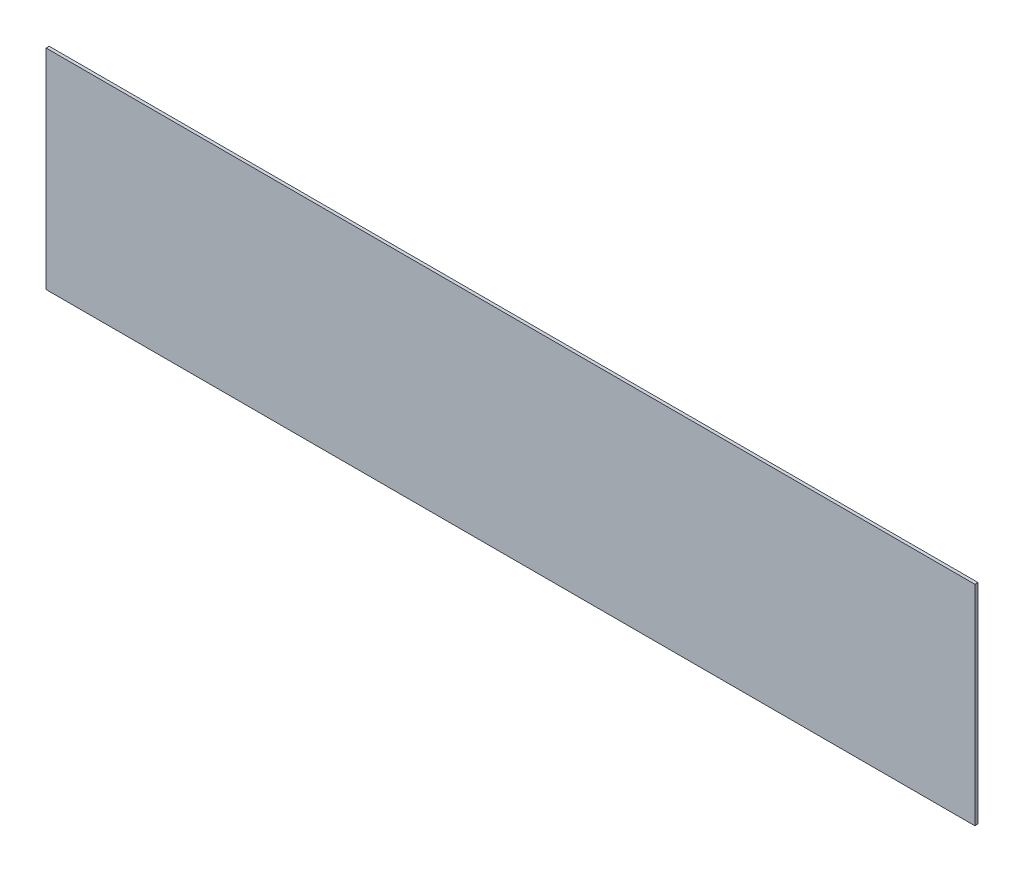
from build123d import *

# Parameters (mm, degrees)
ESBO_O1_W                = 1199
ESBO_O1_H                = 270
RESSALTO_EXTRUS_O1_DEPTH = 4


with BuildPart() as part:
    # Esboço1 → Ressalto-extrusão1 (new body)
    with BuildSketch(Plane.XY):
        Rectangle(ESBO_O1_W, ESBO_O1_H)
    extrude(amount=RESSALTO_EXTRUS_O1_DEPTH)


solid = part.part
